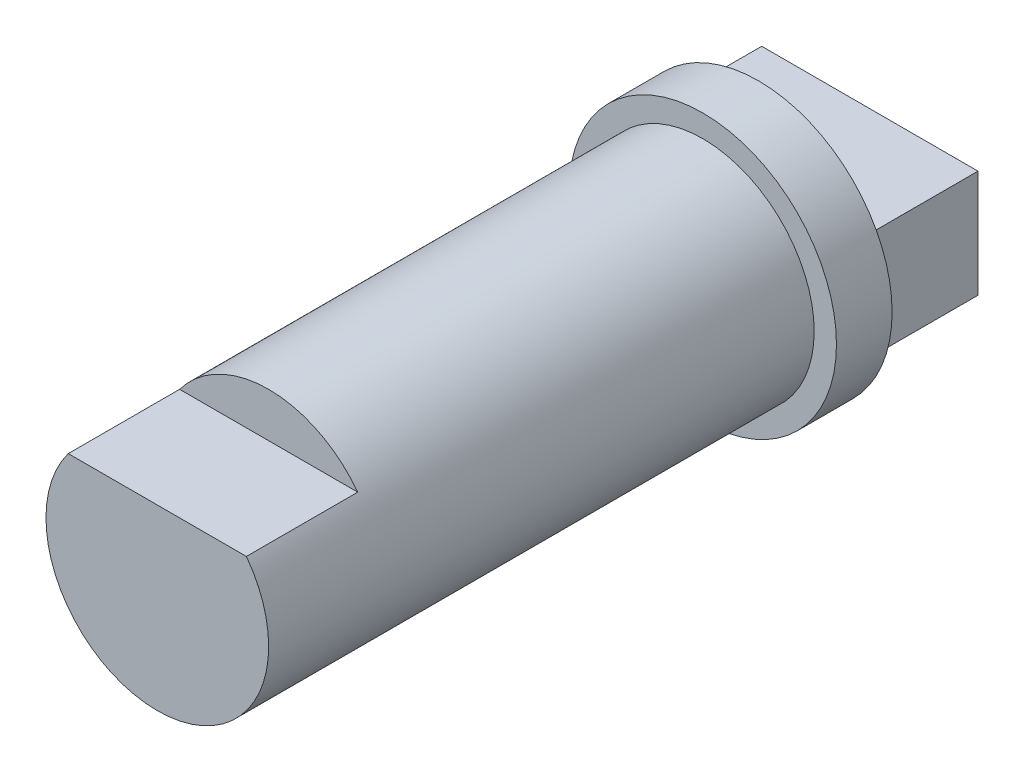
from build123d import *

# Parameters (mm, degrees)
SKETCH1_R           = 10
BOSS_EXTRUDE1_DEPTH = 49
SKETCH2_R           = 12
BOSS_EXTRUDE2_DEPTH = 5
CUT_EXTRUDE1_DEPTH  = 10
SKETCH4_W           = 19.428573608
SKETCH4_H           = 9.65531402
BOSS_EXTRUDE3_DEPTH = 10


with BuildPart() as part:
    # Sketch1 → Boss-Extrude1 (new body)
    with BuildSketch(Plane.XY):
        Circle(SKETCH1_R)
    extrude(amount=BOSS_EXTRUDE1_DEPTH)

    # Sketch2 → Boss-Extrude2 (add)
    with BuildSketch(Plane(origin=(0, 0, 0), x_dir=(-1, 0, 0), z_dir=(0, 0, -1))):
        Circle(SKETCH2_R)
    extrude(amount=BOSS_EXTRUDE2_DEPTH)

    # Sketch3 → Cut-Extrude1 (cut)
    with BuildSketch(Plane.XY.offset(49)):
        with BuildLine():
            Line((0, 6), (8, 6))
            ThreePointArc((8, 6), (0, 10), (-8, 6))
            Line((-8, 6), (0, 6))
        make_face()
    extrude(amount=-CUT_EXTRUDE1_DEPTH, mode=Mode.SUBTRACT)

    # Sketch4 → Boss-Extrude3 (add)
    with BuildSketch(Plane(origin=(0, 0, -5), x_dir=(-1, 0, 0), z_dir=(0, 0, -1))):
        Rectangle(SKETCH4_W, SKETCH4_H)
    extrude(amount=BOSS_EXTRUDE3_DEPTH)


solid = part.part
